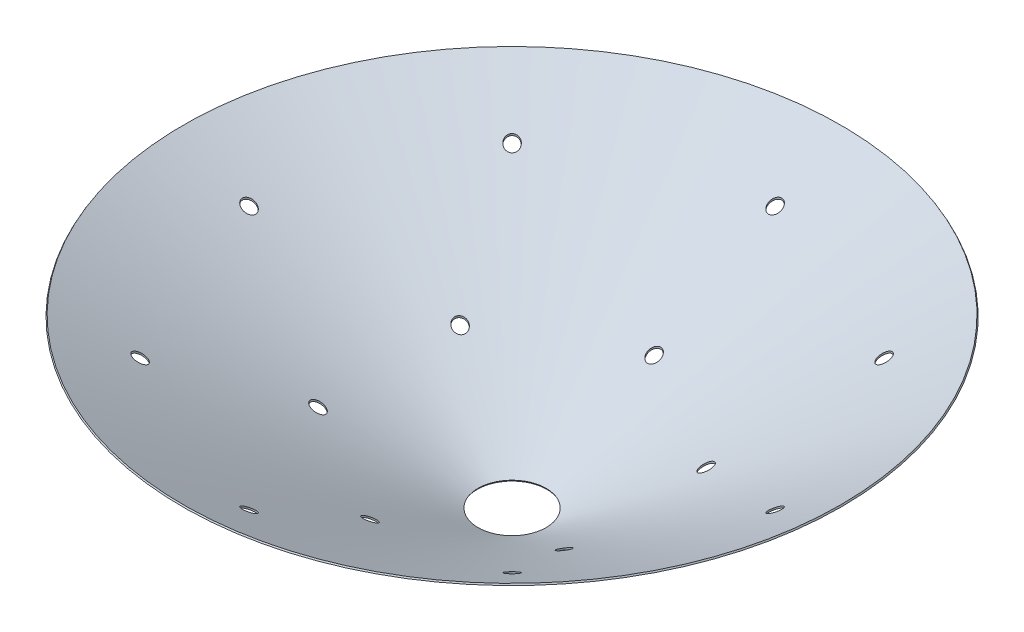
from build123d import *

# Parameters (mm, degrees)
SKIZZE2_R                       = 12.5
SCHNITT_LINEAR_AUSTRAGEN1_DEPTH = 742.339455261


with BuildPart() as part:
    # Skizze1 → Rotation1 (revolve)
    with BuildSketch(Plane.XY, mode=Mode.PRIVATE) as rotation1_sk:
        Polygon((-626.479836193, 882.390386074), (-625, 885), (-64.7, 567.270158665), (-66.179836193, 564.660544739), align=None)
    revolve(rotation1_sk.sketch.rotate(Axis((0, 0, 0), (0, 1, 0)), 180), axis=Axis((0, 0, 0), (0, 1, 0)))  # turned: the seam where the file's is

    # Skizze2 → Schnitt-Linear austragen1 (cut, through all)
    with BuildSketch(Plane(origin=(0, 1306, 0), x_dir=(1, 0, 0), z_dir=(0, 1, 0))):
        with Locations(Location((-353.553390593, -353.553390593, 0), (0, 0, 45))):  # turned: the seam where the file's is
            Circle(SKIZZE2_R)
        with Locations(Location((-500, 0, 0), (0, 0, 122.567467673))):  # turned: the seam where the file's is
            Circle(SKIZZE2_R)
        with Locations(Location((-353.553390593, 353.553390593, 0), (0, 0, 315))):  # turned: the seam where the file's is
            Circle(SKIZZE2_R)
        with Locations(Location((-233.826859022, 135, 0), (0, 0, 165.910648703))):  # turned: the seam where the file's is
            Circle(SKIZZE2_R)
        with Locations(Location((-233.826859022, -135, 0), (0, 0, 128.545663948))):  # turned: the seam where the file's is
            Circle(SKIZZE2_R)
        with Locations(Location((0, -270, 0), (0, 0, 128.570876654))):  # turned: the seam where the file's is
            Circle(SKIZZE2_R)
        with Locations(Location((0, -500, 0), (0, 0, 138.426871448))):  # turned: the seam where the file's is
            Circle(SKIZZE2_R)
        with Locations(Location((0, 270, 0), (0, 0, 146.541547407))):  # turned: the seam where the file's is
            Circle(SKIZZE2_R)
        with Locations(Location((0, 500, 0), (0, 0, 148.886078631))):  # turned: the seam where the file's is
            Circle(SKIZZE2_R)
        with Locations(Location((353.553390593, 353.553390593, 0), (0, 0, 225))):  # turned: the seam where the file's is
            Circle(SKIZZE2_R)
        with Locations(Location((233.826859022, 135, 0), (0, 0, 136.080249851))):  # turned: the seam where the file's is
            Circle(SKIZZE2_R)
        with Locations(Location((233.826859022, -135, 0), (0, 0, 138.782332879))):  # turned: the seam where the file's is
            Circle(SKIZZE2_R)
        with Locations(Location((353.553390593, -353.553390593, 0), (0, 0, 135))):  # turned: the seam where the file's is
            Circle(SKIZZE2_R)
        with Locations(Location((500, 0, 0), (0, 0, 179.999999986))):  # turned: the seam where the file's is
            Circle(SKIZZE2_R)
    extrude(amount=-SCHNITT_LINEAR_AUSTRAGEN1_DEPTH, mode=Mode.SUBTRACT)


solid = part.part
